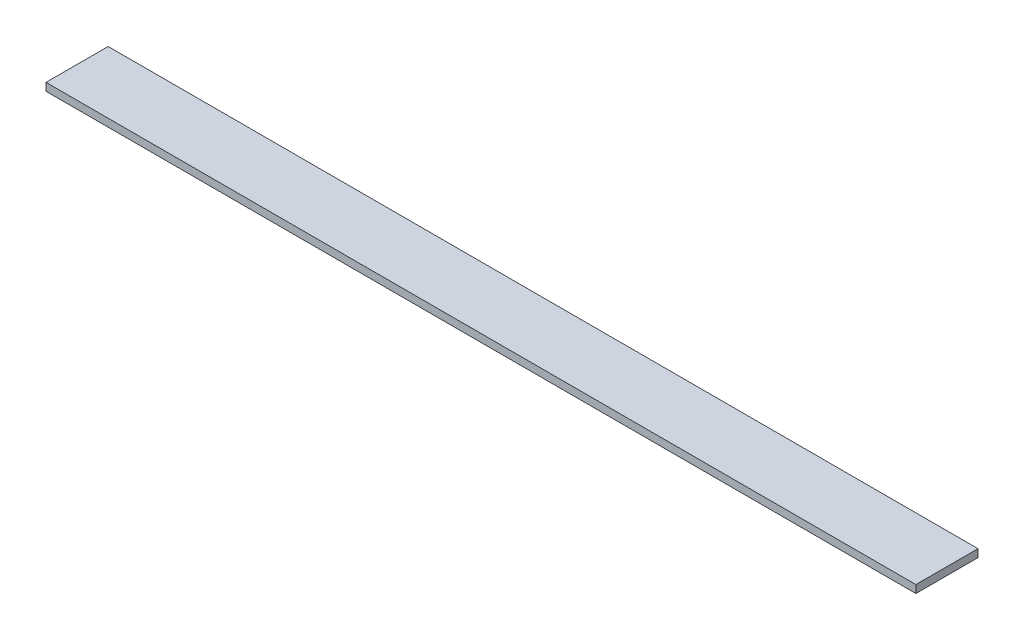
from build123d import *

# Parameters (mm, degrees)
SKETCH1_W           = 355.6
SKETCH1_H           = 25.4
BOSS_EXTRUDE1_DEPTH = 3.175


with BuildPart() as part:
    # Sketch1 → Boss-Extrude1 (new body)
    with BuildSketch(Plane(origin=(0, 0, 0), x_dir=(1, 0, 0), z_dir=(0, 1, 0))):
        with Locations((126.764672963, 8.951350864)):
            Rectangle(SKETCH1_W, SKETCH1_H)
    extrude(amount=BOSS_EXTRUDE1_DEPTH)


solid = part.part
